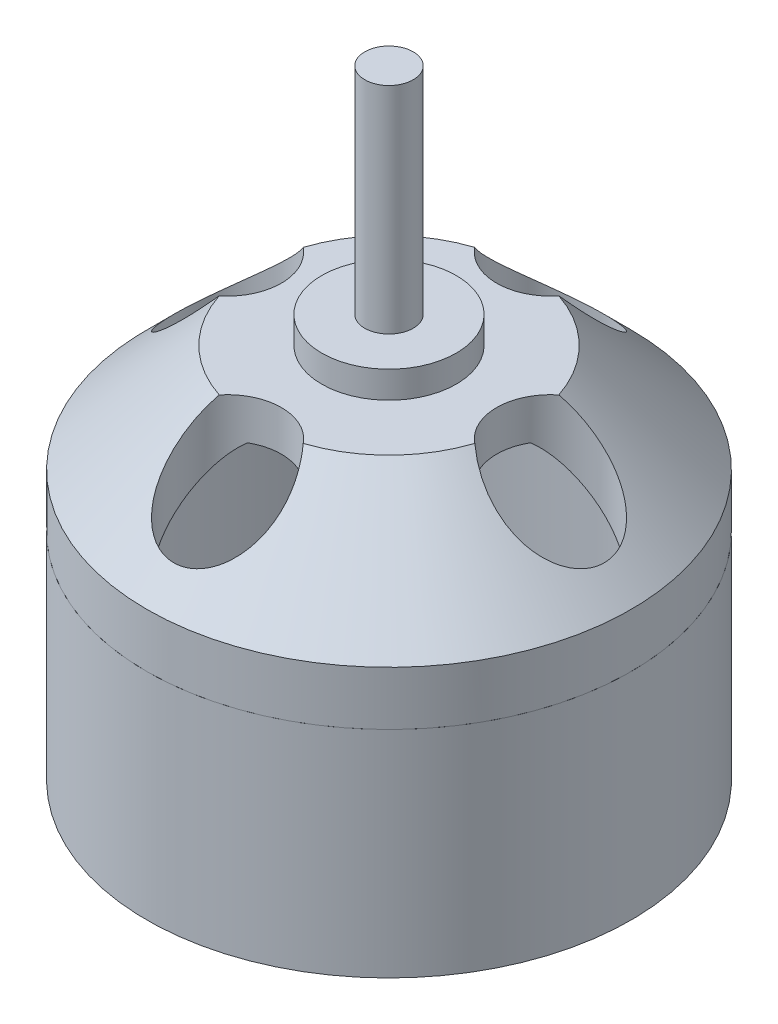
from build123d import *

# Parameters (mm, degrees)
IZIM2_R                          = 9
Y_KSEKLIK_EKSTR_ZYON1_DEPTH      = 1
IZIM3_R                          = 9
Y_KSEKLIK_EKSTR_ZYON2_DEPTH      = 5
PAH1_SIZE                        = 4
BO_ALTMA1_T                      = -1.5
IZIM5_R                          = 2
KES_EKSTR_ZYON1_DEPTH            = 6
IZIM7_R                          = 2.5
Y_KSEKLIK_EKSTR_ZYON4_DEPTH      = 1
IZIM6_R                          = 9
IZIM6_R_2                        = 8.5
Y_KSEKLIK_EKSTR_ZYON6_DEPTH      = 8
IZIM8_R                          = 0.9
Y_KSEKLIK_EKSTR_ZYON7_DEPTH      = 8
Y_KSEKLIK_EKSTR_ZYON7_DEPTH_BACK = 20


with BuildPart() as part:
    # Çizim2 → Yükseklik-Ekstrüzyon1 (new body)
    with BuildSketch(Plane(origin=(0, 0, 0), x_dir=(1, 0, 0), z_dir=(0, 1, 0))):
        with Locations(Location((0, 0, 0), (0, 0, 270))):
            Circle(IZIM2_R)
    extrude(amount=Y_KSEKLIK_EKSTR_ZYON1_DEPTH)

    # Çizim3 → Yükseklik-Ekstrüzyon2 (add)
    with BuildSketch(Plane(origin=(0, 1, 0), x_dir=(1, 0, 0), z_dir=(0, 1, 0))):
        with Locations(Location((0, 0, 0), (0, 0, 270))):
            Circle(IZIM3_R)
    extrude(amount=Y_KSEKLIK_EKSTR_ZYON2_DEPTH)

    # Pah1
    pah1_edges = [part.edges().sort_by_distance(p)[0] for p in [
        (0, 6, -9),
    ]]
    chamfer(pah1_edges, length=PAH1_SIZE)

    # İç Boşaltma1
    bo_altma1_openings = [part.faces().sort_by_distance(p)[0] for p in [
        (0, 0, 0),
    ]]
    offset(amount=BO_ALTMA1_T, openings=bo_altma1_openings, kind=Kind.INTERSECTION)

    # Çizim5 → Kes-Ekstrüzyon1 (cut)
    with BuildSketch(Plane(origin=(0, 6, 0), x_dir=(1, 0, 0), z_dir=(0, 1, 0))):
        with Locations(Location((0, -6, 0), (0, 0, 317.383857291))):
            Circle(IZIM5_R)
        with Locations(Location((-6, 0, 0), (0, 0, 308.682187453))):
            Circle(IZIM5_R)
        with Locations(Location((0, 6, 0), (0, 0, 240.203813537))):
            Circle(IZIM5_R)
        with Locations(Location((6, 0, 0), (0, 0, 231.317810635))):
            Circle(IZIM5_R)
    extrude(amount=-KES_EKSTR_ZYON1_DEPTH, mode=Mode.SUBTRACT)

    # Çizim7 → Yükseklik-Ekstrüzyon4 (add)
    with BuildSketch(Plane(origin=(0, 6, 0), x_dir=(1, 0, 0), z_dir=(0, 1, 0))):
        with Locations(Location((0, 0, 0), (0, 0, 270))):
            Circle(IZIM7_R)
    extrude(amount=Y_KSEKLIK_EKSTR_ZYON4_DEPTH)


with BuildPart() as body_2:
    # Çizim6 → Yükseklik-Ekstrüzyon6 (new body)
    with BuildSketch(Plane.XZ):
        with Locations(Location((0, 0, 0), (0, 0, 270))):
            Circle(IZIM6_R)
        with Locations(Location((0, 0, 0), (0, 0, 270))):
            Circle(IZIM6_R_2, mode=Mode.SUBTRACT)
    extrude(amount=Y_KSEKLIK_EKSTR_ZYON6_DEPTH)


with BuildPart() as body_3:
    # Çizim8 → Yükseklik-Ekstrüzyon7 (new, two sides)
    with BuildSketch(Plane(origin=(0, 7, 0), x_dir=(1, 0, 0), z_dir=(0, 1, 0))) as y_kseklik_ekstr_zyon7_sk:
        with Locations(Location((0, 0, 0), (0, 0, 270))):
            Circle(IZIM8_R)
    extrude(amount=Y_KSEKLIK_EKSTR_ZYON7_DEPTH)
    extrude(y_kseklik_ekstr_zyon7_sk.sketch, amount=-Y_KSEKLIK_EKSTR_ZYON7_DEPTH_BACK)


solid = Compound([part.part, body_2.part, body_3.part])
